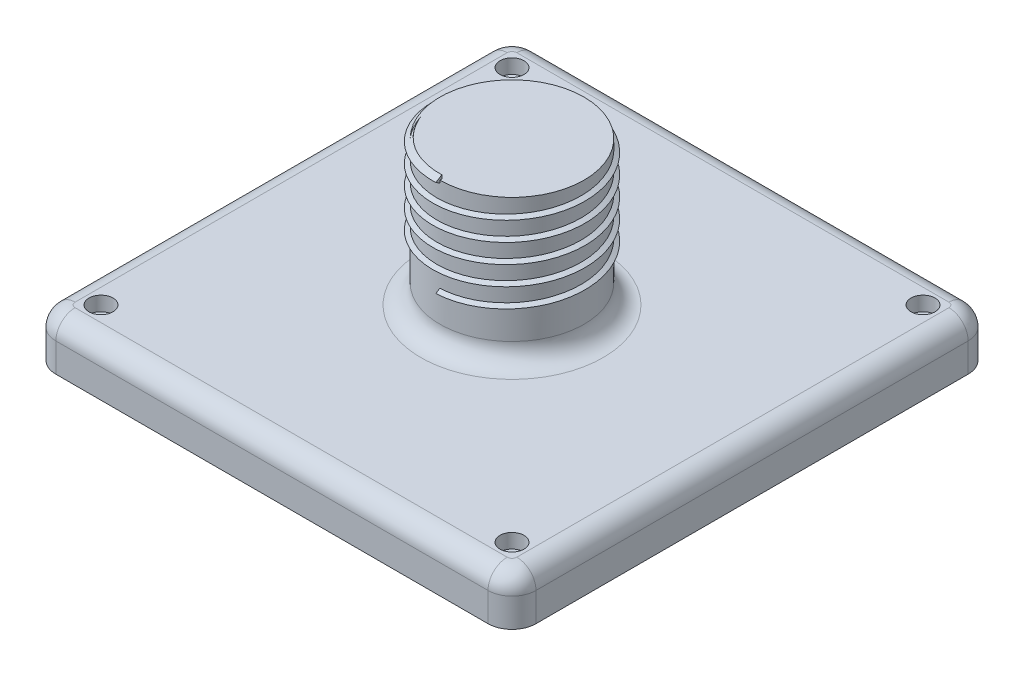
from build123d import *

# Parameters (mm, degrees)
SKETCH1_R                        = 1
BASE_DEPTH                       = 10
BASE_REDONDEDO_R                 = 4
SKETCH4_R                        = 2.5
CUT_EXTRUDE1_DEPTH               = 3
SKETCH5_R                        = 15
SALIENTE_DEPTH                   = 30
ROSCA_PITCH                      = 4
ROSCA_HEIGHT                     = 20
ROSCA_RADIUS                     = 15
ROSCA_START_ANGLE                = 180
REDONDEO_UNION_BASE_Y_SALIENTE_R = 4


with BuildPart() as part:
    # Sketch1 → base (new body)
    with BuildSketch(Plane(origin=(0, 0, 0), x_dir=(1, 0, 0), z_dir=(0, 1, 0))):
        with BuildLine():
            Line((45, -50), (-45, -50))
            ThreePointArc((-45, -50), (-48.535533906, -48.535533906), (-50, -45))
            Line((-50, -45), (-50, 45))
            ThreePointArc((-50, 45), (-48.535533906, 48.535533906), (-45, 50))
            Line((-45, 50), (45, 50))
            ThreePointArc((45, 50), (48.535533906, 48.535533906), (50, 45))
            Line((50, 45), (50, -45))
            ThreePointArc((50, -45), (48.535533906, -48.535533906), (45, -50))
        make_face()
        with Locations((-42.804308955, 42.804308955)):
            Circle(SKETCH1_R, mode=Mode.SUBTRACT)
        with Locations((42.804308955, -42.804308955)):
            Circle(SKETCH1_R, mode=Mode.SUBTRACT)
        with Locations((42.804308955, 42.804308955)):
            Circle(SKETCH1_R, mode=Mode.SUBTRACT)
        with Locations((-42.804308955, -42.804308955)):
            Circle(SKETCH1_R, mode=Mode.SUBTRACT)
    extrude(amount=BASE_DEPTH)

    # base redondedo
    base_redondedo_edges = [part.edges().sort_by_distance(p)[0] for p in [
        (48.535533906, 10, 48.535533906),
        (50, 10, 0),
        (48.535533906, 10, -48.535533906),
        (0, 10, -50),
        (-48.535533906, 10, -48.535533906),
        (-50, 10, 0),
        (-48.535533906, 10, 48.535533906),
        (0, 10, 50),
    ]]
    fillet(base_redondedo_edges, radius=BASE_REDONDEDO_R)

    # Sketch4 → Cut-Extrude1 (cut)
    with BuildSketch(Plane(origin=(0, 10, 0), x_dir=(1, 0, 0), z_dir=(0, 1, 0))):
        with Locations((-42.804308955, 42.804308955)):
            Circle(SKETCH4_R)
        with Locations((42.804308955, 42.804308955)):
            Circle(SKETCH4_R)
        with Locations((42.804308955, -42.804308955)):
            Circle(SKETCH4_R)
        with Locations((-42.804308955, -42.804308955)):
            Circle(SKETCH4_R)
    extrude(amount=-CUT_EXTRUDE1_DEPTH, mode=Mode.SUBTRACT)

    # Sketch5 → saliente (add)
    with BuildSketch(Plane(origin=(0, 10, 0), x_dir=(1, 0, 0), z_dir=(0, 1, 0))):
        Circle(SKETCH5_R)
    extrude(amount=SALIENTE_DEPTH)

    # rosca: sweep along a helix
    with BuildLine() as rosca_path:
        add(Helix(ROSCA_PITCH, ROSCA_HEIGHT, ROSCA_RADIUS, center=(0, 40, 0), direction=(0, -1, 0), mode=Mode.PRIVATE).rotate(Axis((0, 40, 0), (0, -1, 0)), ROSCA_START_ANGLE))
    # Sketch15 → rosca (sweep)
    with BuildSketch(Plane(origin=(0, 40, 15), x_dir=(0, 0, 1), z_dir=(-0.999100582, -0.042403146, 0))):
        Polygon((-0.433012702, 0.75), (-0.433012702, -0.75), (0.866025404, 0), align=None)
    sweep(path=rosca_path.line, is_frenet=True)

    # redondeo union base y saliente
    redondeo_union_base_y_saliente_edges = [part.edges().sort_by_distance(p)[0] for p in [
        (-15, 10, 0),
    ]]
    fillet(redondeo_union_base_y_saliente_edges, radius=REDONDEO_UNION_BASE_Y_SALIENTE_R)


solid = part.part
